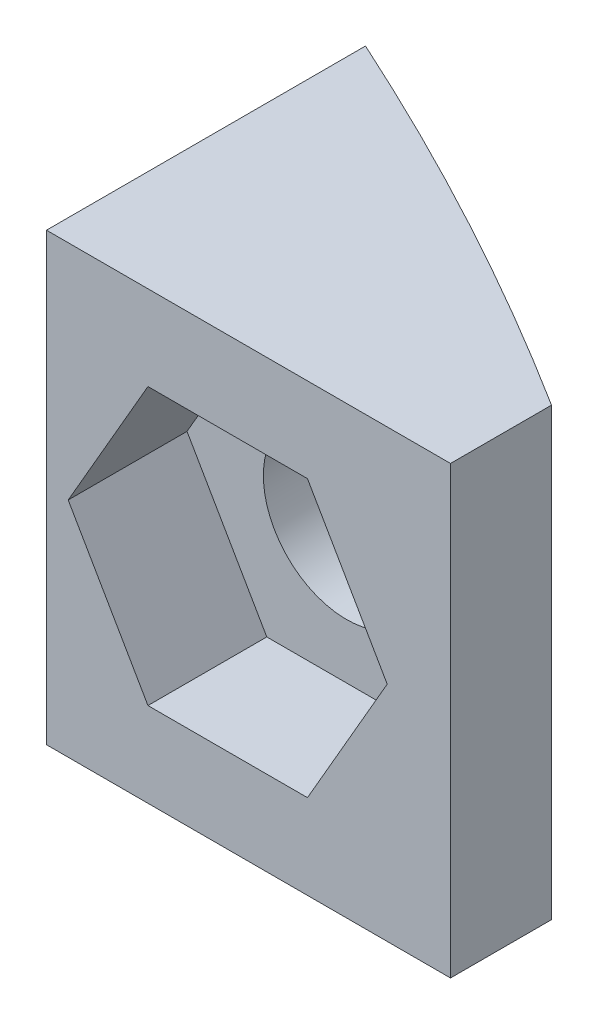
from build123d import *

# Parameters (mm, degrees)
BOSS_EXTRUDE1_DEPTH     = 19.05
CUT_EXTRUDE1_DEPTH      = 5.08
CUT_EXTRUDE2_REACH      = 82.935
CUT_EXTRUDE2_END_RADIUS = 145.288
SKETCH2_3_R             = 3.556


with BuildPart() as part:
    # Sketch1 → Boss-Extrude1 (new body)
    with BuildSketch(Plane(origin=(0, 0, 0), x_dir=(1, 0, 0), z_dir=(0, 1, 0))):
        with BuildLine():
            ThreePointArc((77.47, 122.910544885), (68.991544122, 127.862307909), (60.198, 132.230116615))
            Line((60.198, 132.230116615), (60.198, 118.592544885))
            Line((60.198, 118.592544885), (77.47, 118.592544885))
            Line((77.47, 118.592544885), (77.47, 122.910544885))
        make_face()
    extrude(amount=BOSS_EXTRUDE1_DEPTH)

    # Sketch2 → Cut-Extrude1 (cut)
    with BuildSketch(Plane.XY.offset(-118.592544885)):
        Polygon((71.354542015, 3.6195), (74.764084029, 9.525), (71.354542015, 15.4305), (64.535457985, 15.4305), (61.125915971, 9.525), (64.535457985, 3.6195), align=None)
    extrude(amount=-CUT_EXTRUDE1_DEPTH, mode=Mode.SUBTRACT)

    # Cut-Extrude2: up to this cylinder (the profile starts inside it)
    cut_extrude2_end = Plane(origin=(0, 9.525, 0), z_dir=(0, -1, 0)) * Cylinder(CUT_EXTRUDE2_END_RADIUS, 457.446, mode=Mode.PRIVATE)
    # Sketch2_3 → Cut-Extrude2 (cut, up to the surface)
    with BuildSketch(Plane.XY.offset(-118.592544885), mode=Mode.PRIVATE) as cut_extrude2_sk1:
        with Locations((67.945, 9.525)):
            Circle(SKETCH2_3_R)
    cut_extrude2_tool1 = extrude(cut_extrude2_sk1.sketch, amount=-CUT_EXTRUDE2_REACH, mode=Mode.PRIVATE) & cut_extrude2_end
    add(cut_extrude2_tool1.solids().sort_by_distance((67.945, 9.525, -118.592545))[0], mode=Mode.SUBTRACT)


solid = part.part
